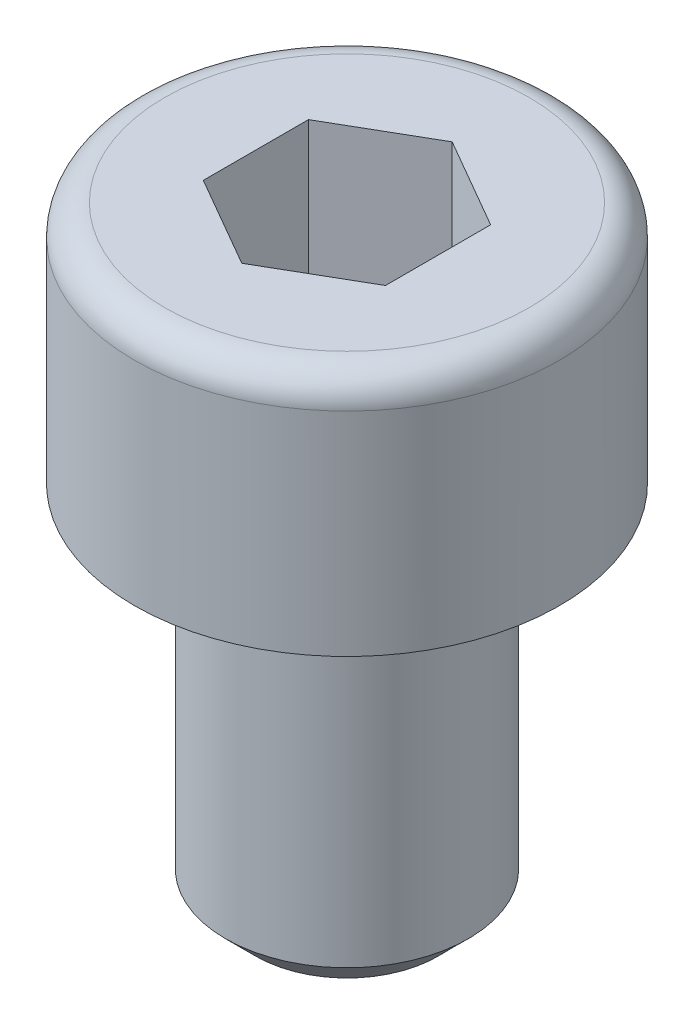
from build123d import *

# Parameters (mm, degrees)
CORTAR_EXTRUIR1_DEPTH = 3
CHAFL_N1_SIZE         = 0.5
REDONDEO1_R           = 0.5


with BuildPart() as part:
    # Croquis1 → Revolución1 (revolve)
    with BuildSketch(Plane.XY):
        Polygon((0, 0), (3.5, 0), (3.5, -4), (2, -4), (2, -10), (0, -10), align=None)
    revolve(axis=Axis((0, 0, 0), (0, -1, 0)))

    # Croquis2 → Cortar-Extruir1 (cut)
    with BuildSketch(Plane(origin=(0, 0, 0), x_dir=(1, 0, 0), z_dir=(0, 1, 0))):
        Polygon((1.5, 0.866025404), (0, 1.732050808), (-1.5, 0.866025404), (-1.5, -0.866025404), (0, -1.732050808), (1.5, -0.866025404), align=None)
    extrude(amount=-CORTAR_EXTRUIR1_DEPTH, mode=Mode.SUBTRACT)

    # Chaflán1
    chafl_n1_edges = [part.edges().sort_by_distance(p)[0] for p in [
        (-2, -10, 0),
    ]]
    chamfer(chafl_n1_edges, length=CHAFL_N1_SIZE)

    # Redondeo1
    redondeo1_edges = [part.edges().sort_by_distance(p)[0] for p in [
        (-3.5, 0, 0),
    ]]
    fillet(redondeo1_edges, radius=REDONDEO1_R)


solid = part.part
